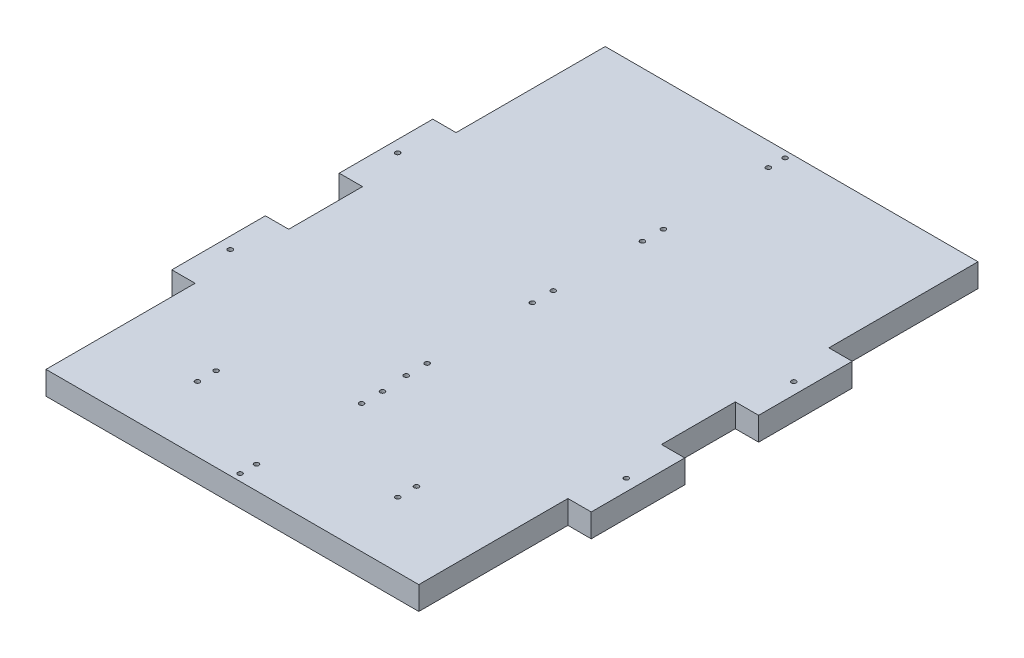
from build123d import *

# Parameters (mm, degrees)
SKETCH1_W           = 101.6
SKETCH1_H           = 152.4
BOSS_EXTRUDE1_DEPTH = 6.35
SKETCH2_W           = 25.498289586
SKETCH2_H           = 6.35
BOSS_EXTRUDE2_DEPTH = 6.35
SKETCH3_W           = 25.498289586
SKETCH3_H           = 6.35
BOSS_EXTRUDE3_DEPTH = 6.35
SKETCH4_R           = 0.635
CUT_EXTRUDE1_DEPTH  = 6.35
SKETCH5_R           = 0.635
CUT_EXTRUDE2_DEPTH  = 7.35
SKETCH7_R           = 0.635
CUT_EXTRUDE3_DEPTH  = 7.35
SKETCH9_R           = 0.635
CUT_EXTRUDE4_DEPTH  = 7.35


with BuildPart() as part:
    # Sketch1 → Boss-Extrude1 (new body)
    with BuildSketch(Plane(origin=(0, 0, 0), x_dir=(1, 0, 0), z_dir=(0, 1, 0))):
        with Locations((50.8, 76.2)):
            Rectangle(SKETCH1_W, SKETCH1_H)
    extrude(amount=BOSS_EXTRUDE1_DEPTH)

    # Sketch2 → Boss-Extrude2 (add)
    with BuildSketch(Plane(origin=(101.6, 0, 0), x_dir=(0, 0, -1), z_dir=(1, 0, 0))):
        with Locations((53.389144793, 3.175)):
            Rectangle(SKETCH2_W, SKETCH2_H)
        with Locations((99.010855207, 3.175)):
            Rectangle(SKETCH2_W, SKETCH2_H)
    extrude(amount=BOSS_EXTRUDE2_DEPTH)

    # Sketch3 → Boss-Extrude3 (add)
    with BuildSketch(Plane.ZY):
        with Locations((-99.010855207, 3.175)):
            Rectangle(SKETCH3_W, SKETCH3_H)
        with Locations((-53.389144793, 3.175)):
            Rectangle(SKETCH3_W, SKETCH3_H)
    extrude(amount=BOSS_EXTRUDE3_DEPTH)

    # Sketch4 → Cut-Extrude1 (cut)
    with BuildSketch(Plane.XZ):
        with Locations((-3.175, -53.389144793)):
            Circle(SKETCH4_R)
        with Locations((-3.175, -99.010855207)):
            Circle(SKETCH4_R)
        with Locations((104.775, -53.389144793)):
            Circle(SKETCH4_R)
        with Locations((104.775, -99.010855207)):
            Circle(SKETCH4_R)
    extrude(amount=-CUT_EXTRUDE1_DEPTH, mode=Mode.SUBTRACT)

    # Sketch5 → Cut-Extrude2 (cut, through all)
    with BuildSketch(Plane.XZ):
        with Locations((51.054, -6.304558397)):
            Circle(SKETCH5_R)
        with Locations((51.054001096, -34.940813016)):
            Circle(SKETCH5_R)
        with Locations((51.054, -40.655813016)):
            Circle(SKETCH5_R)
        with Locations((51.054, -1.859558397)):
            Circle(SKETCH5_R)
        with Locations((50.530750765, -87.704154674)):
            Circle(SKETCH5_R)
        with Locations((50.546, -47.628968946)):
            Circle(SKETCH5_R)
        with Locations((50.546, -53.343968946)):
            Circle(SKETCH5_R)
        with Locations((50.544258636, -81.989170638)):
            Circle(SKETCH5_R)
        with Locations((51.054, -111.498317742)):
            Circle(SKETCH5_R)
        with Locations((51.054, -117.213317742)):
            Circle(SKETCH5_R)
    extrude(amount=-CUT_EXTRUDE2_DEPTH, mode=Mode.SUBTRACT)

    # Sketch7 → Cut-Extrude3 (cut, through all)
    with BuildSketch(Plane(origin=(0, 6.35, 0), x_dir=(1, 0, 0), z_dir=(0, 1, 0))):
        with Locations((23.495, 17.78)):
            Circle(SKETCH7_R)
        with Locations((23.495, 22.86)):
            Circle(SKETCH7_R)
        with Locations((78.105, 22.86)):
            Circle(SKETCH7_R)
        with Locations((78.105, 17.78)):
            Circle(SKETCH7_R)
    extrude(amount=-CUT_EXTRUDE3_DEPTH, mode=Mode.SUBTRACT)

    # Sketch9 → Cut-Extrude4 (cut, through all)
    with BuildSketch(Plane(origin=(0, 6.35, 0), x_dir=(1, 0, 0), z_dir=(0, 1, 0))):
        with Locations((50.8, 150.622)):
            Circle(SKETCH9_R)
        with Locations((50.8, 146.05)):
            Circle(SKETCH9_R)
    extrude(amount=-CUT_EXTRUDE4_DEPTH, mode=Mode.SUBTRACT)


solid = part.part
